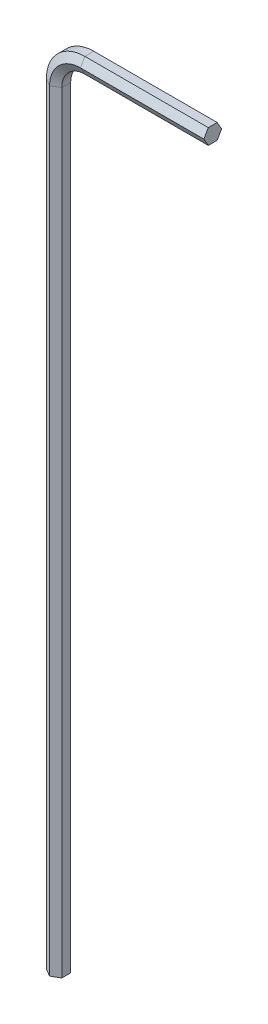
from build123d import *


with BuildPart() as part:
    # 6mm: sweep along a path in Sketch1
    with BuildLine(Plane.XY) as f_6mm_path:
        Line((0, 0), (-12, 0))
        ThreePointArc((-12, 0), (-14.121320344, -0.878679656), (-15, -3))
        Line((-15, -3), (-15, -78))
    # Sketch 6m → 6mm (sweep)
    with BuildSketch(Plane(origin=(0, 0, 0), x_dir=(0, 0, -1), z_dir=(1, 0, 0))):
        Polygon((-0.866025404, 0), (-0.433012702, -0.75), (0.433012702, -0.75), (0.866025404, 0), (0.433012702, 0.75), (-0.433012702, 0.75), align=None)
    sweep(path=f_6mm_path.line)


solid = part.part
